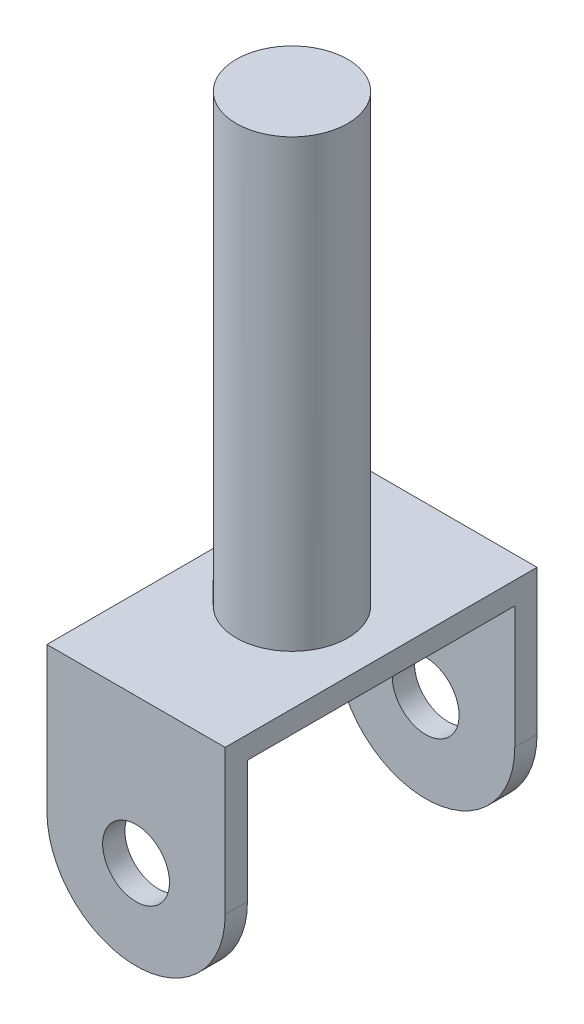
from build123d import *

# Parameters (mm, degrees)
ESQUISSE1_R      = 1.5
EXTRUSION1_DEPTH = 14
ESQUISSE2_R      = 2.5
EXTRUSION2_DEPTH = 20
ESQUISSE5_W      = 12
ESQUISSE5_H      = 9.78359792
EXTRUSION4_DEPTH = 20


with BuildPart() as part:
    # Esquisse1 → Extrusion1 (new body)
    with BuildSketch(Plane.XY):
        with BuildLine():
            Line((0, 3.5), (0, 10))
            Line((0, 10), (8, 10))
            Line((8, 10), (8, 3.5))
            ThreePointArc((8, 3.5), (4, -0.5), (0, 3.5))
        make_face()
        with Locations((4, 3.5)):
            Circle(ESQUISSE1_R, mode=Mode.SUBTRACT)
    extrude(amount=EXTRUSION1_DEPTH)

    # Esquisse2 → Extrusion2 (add)
    with BuildSketch(Plane(origin=(0, 10, 0), x_dir=(1, 0, 0), z_dir=(0, 1, 0))):
        with Locations((4, -7)):
            Circle(ESQUISSE2_R)
    extrude(amount=EXTRUSION2_DEPTH)

    # Esquisse5 → Extrusion4 (cut)
    with BuildSketch(Plane.ZY):
        with Locations((7, 4.10820104)):
            Rectangle(ESQUISSE5_W, ESQUISSE5_H)
    extrude(amount=-EXTRUSION4_DEPTH, mode=Mode.SUBTRACT)


solid = part.part
